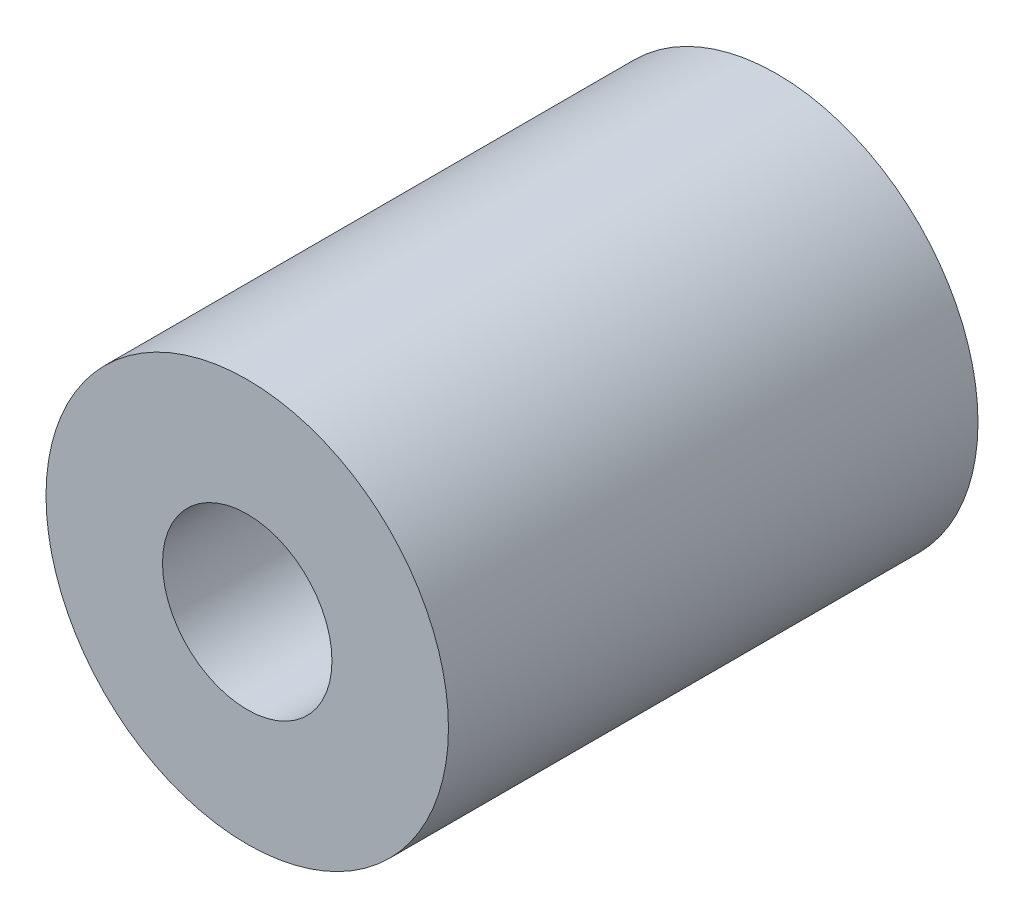
from build123d import *

# Parameters (mm, degrees)
SKETCH1_R           = 9.5
BOSS_EXTRUDE1_DEPTH = 25
SKETCH2_R           = 4
CUT_EXTRUDE1_DEPTH  = 10
SKETCH3_R           = 2.5
CUT_EXTRUDE2_DEPTH  = 10


with BuildPart() as part:
    # Sketch1 → Boss-Extrude1 (new body)
    with BuildSketch(Plane.XY):
        Circle(SKETCH1_R)
    extrude(amount=BOSS_EXTRUDE1_DEPTH)

    # Sketch2 → Cut-Extrude1 (cut)
    with BuildSketch(Plane.XY.offset(25)):
        Circle(SKETCH2_R)
    extrude(amount=-CUT_EXTRUDE1_DEPTH, mode=Mode.SUBTRACT)

    # Sketch3 → Cut-Extrude2 (cut)
    with BuildSketch(Plane(origin=(0, 0, 0), x_dir=(-1, 0, 0), z_dir=(0, 0, -1))):
        Circle(SKETCH3_R)
    extrude(amount=-CUT_EXTRUDE2_DEPTH, mode=Mode.SUBTRACT)


solid = part.part
